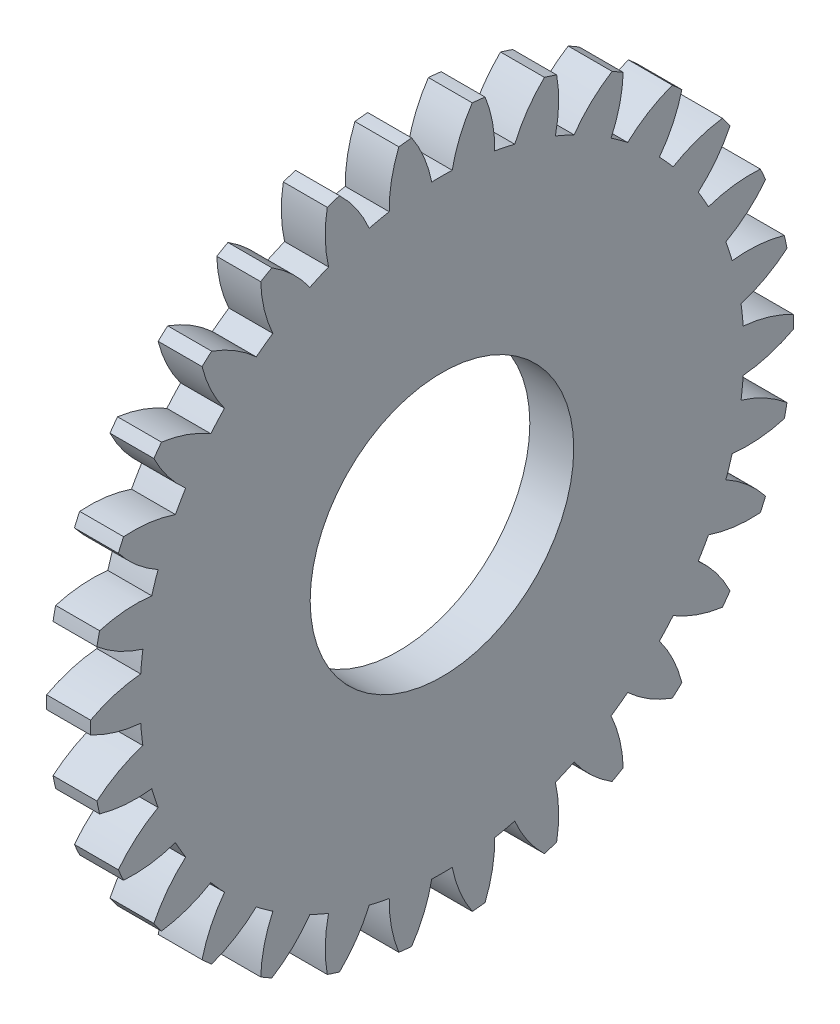
from build123d import *

# Parameters (mm, degrees)
BASPROSKE_W     = 2
BASPROSKE_H     = 16
TOOTHCUT_DEPTH  = 23.715633383
TEETHCUTS_COUNT = 30
BORSKE_R        = 6
BORE_DEPTH      = 50.0000508


with BuildPart() as part:
    # BasProSke → Base-Revolve (revolve)
    with BuildSketch(Plane(origin=(0, 0, 0), x_dir=(1, 0, 0), z_dir=(0, 1, 0)), mode=Mode.PRIVATE) as base_revolve_sk:
        with Locations((1, 8)):
            Rectangle(BASPROSKE_W, BASPROSKE_H)
    revolve(base_revolve_sk.sketch.rotate(Axis((-10, 0, 0), (1, 0, 0)), 180), axis=Axis((-10, 0, 0), (1, 0, 0)))

    # TooCutSke → ToothCut (cut, through all)
    with BuildSketch(Plane(origin=(0, 0, 0), x_dir=(0, 0, -1), z_dir=(1, 0, 0))):
        with BuildLine():
            ThreePointArc((0.466400716, 13.741086979), (0, 13.749), (-0.466400716, 13.741086979))
            ThreePointArc((-0.466400716, 13.741086979), (-0.819142092, 14.899954875), (-1.3974676, 15.964351834))
            ThreePointArc((-1.3974676, 15.964351834), (0, 16.0254), (1.3974676, 15.964351834))
            ThreePointArc((1.3974676, 15.964351834), (0.819142092, 14.899954875), (0.466400716, 13.741086979))
        make_face()
    toothcut = extrude(amount=TOOTHCUT_DEPTH, mode=Mode.SUBTRACT)

    # TeethCuts: ToothCut ×30 about axis
    teethcuts_axis = Axis((0, 0, 0), (1, 0, 0))
    for i in range(1, TEETHCUTS_COUNT):
        add(toothcut.rotate(teethcuts_axis, i * 360 / TEETHCUTS_COUNT), mode=Mode.SUBTRACT)

    # BorSke → Bore (cut, symmetric)
    with BuildSketch(Plane(origin=(0, 0, 0), x_dir=(0, 0, -1), z_dir=(1, 0, 0))):
        with Locations(Location((0, 0, 0), (0, 0, 180))):
            Circle(BORSKE_R)
    extrude(amount=BORE_DEPTH, both=True, mode=Mode.SUBTRACT)


solid = part.part
